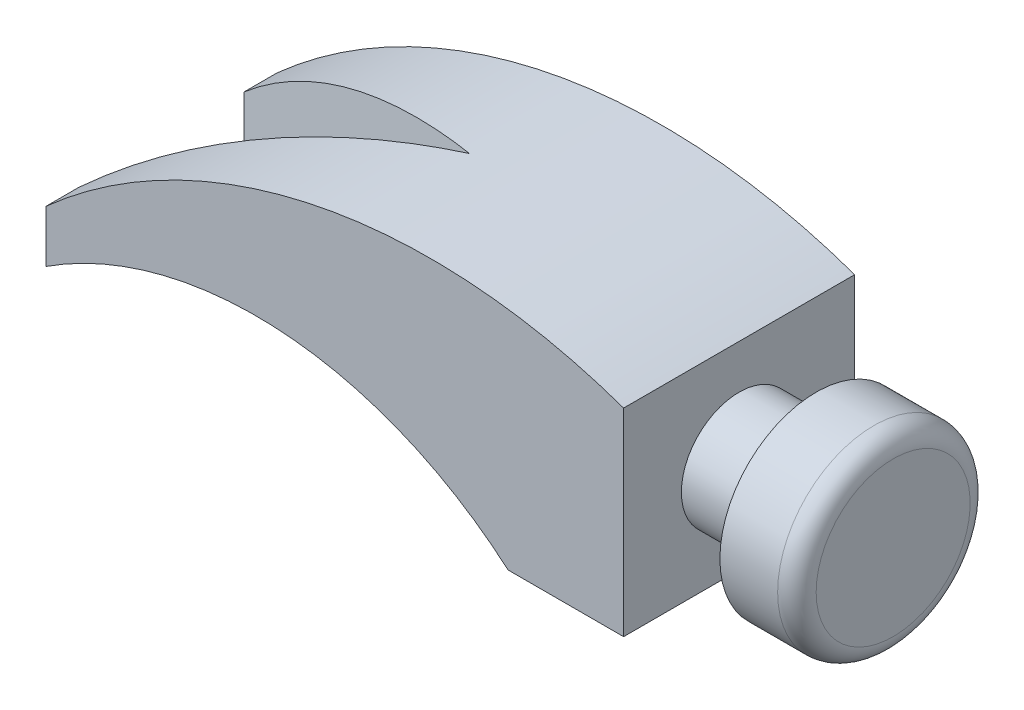
from build123d import *

# Parameters (mm, degrees)
BOSS_EXTRUDE1_DEPTH = 60
CUT_EXTRUDE1_DEPTH  = 50
CUT_EXTRUDE2_DEPTH  = 50


with BuildPart() as part:
    # Sketch1 → Boss-Extrude1 (new body)
    with BuildSketch(Plane.XY):
        with BuildLine():
            Line((49.124764621, -30.033995939), (49.124764621, 21.387360298))
            ThreePointArc((49.124764621, 21.387360298), (-29.932176884, 27.124741995), (-100.875235379, -8.230597064))
            Line((-100.875235379, -8.230597064), (-100.875235379, -21.76381536))
            ThreePointArc((-100.875235379, -21.76381536), (-39.492781079, -5.839547279), (19.124764621, -30.033995939))
            Line((19.124764621, -30.033995939), (49.124764621, -30.033995939))
        make_face()
    extrude(amount=BOSS_EXTRUDE1_DEPTH)

    # Sketch3 → Revolve1 (revolve)
    with BuildSketch(Plane.XY.offset(30)):
        with BuildLine():
            Line((49.124764621, -5.033995939), (49.124764621, 9.966004061))
            Line((49.124764621, 9.966004061), (69.124764621, 9.966004061))
            Line((69.124764621, 9.966004061), (69.124764621, 19.966004061))
            Line((69.124764621, 19.966004061), (84.124764621, 19.966004061))
            ThreePointArc((84.124764621, 19.966004061), (87.660298526, 18.501537967), (89.124764621, 14.966004061))
            Line((89.124764621, 14.966004061), (89.124764621, -5.033995939))
            Line((89.124764621, -5.033995939), (49.124764621, -5.033995939))
        make_face()
    revolve(axis=Axis((49.124764621, -5.033995939, 30), (1, 0, 0)))

    # Sketch5 → Cut-Extrude1 (cut)
    with BuildSketch(Plane(origin=(0, 0, 0), x_dir=(1, 0, 0), z_dir=(0, 1, 0))):
        Polygon((-100.875235379, -8.547870984), (-100.875235379, -51.419743412), (-20.875235379, -30), align=None)
    extrude(amount=-CUT_EXTRUDE1_DEPTH, mode=Mode.SUBTRACT)

    # Sketch6 → Cut-Extrude2 (cut)
    with BuildSketch(Plane.XZ):
        Polygon((-90.829889616, 48.730134303), (-20.875235379, 30), (-90.829889616, 11.24154665), align=None)
    extrude(amount=-CUT_EXTRUDE2_DEPTH, mode=Mode.SUBTRACT)


solid = part.part
